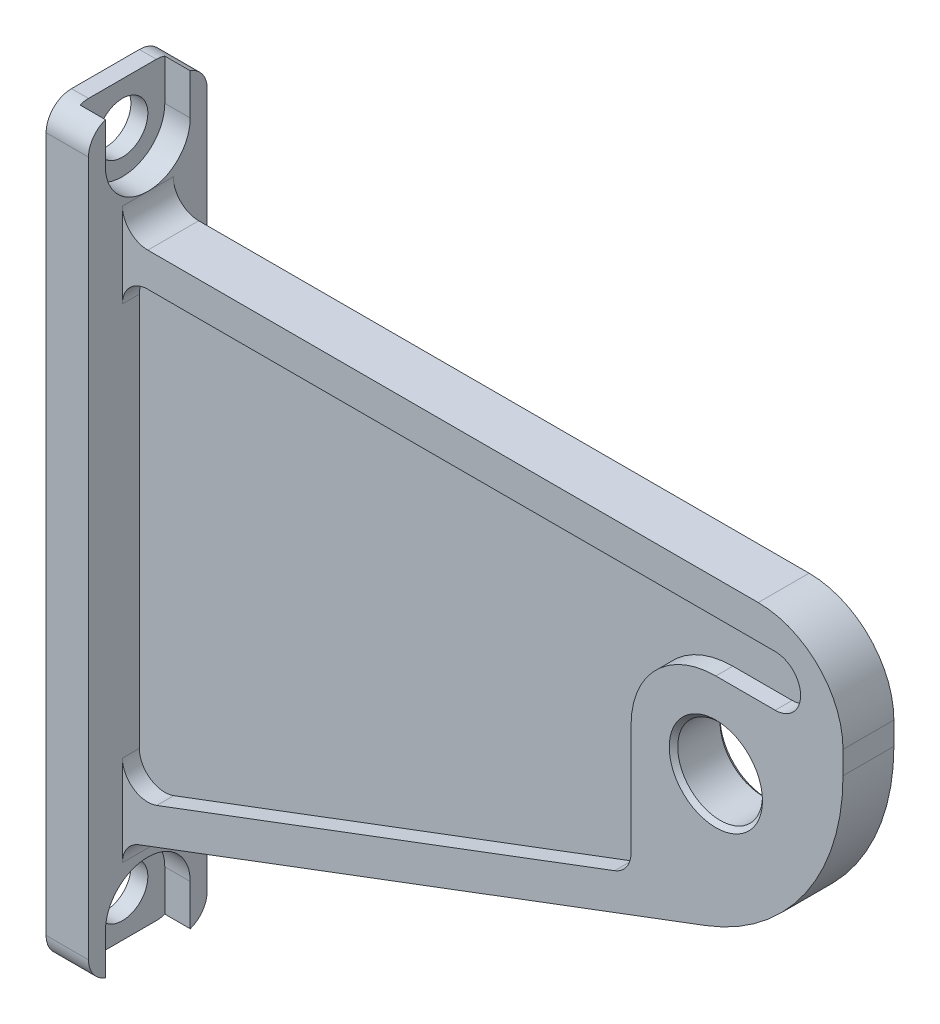
from build123d import *

# Parameters (mm, degrees)
EXTRUDE_2_DEPTH     = 7
SKETCH_2_10_R       = 5
EXTRUDE_6_DEPTH     = 3
EXTRUDE_7_DEPTH     = 1
SKETCH_5_R          = 3
CUT_EXTRUDE_1_DEPTH = 3
SKETCH_5_5_R        = 3
CUT_EXTRUDE_2_DEPTH = 123.547949799
FILLET_1_R          = 3
CHAMFER_2_SIZE      = 0.5


with BuildPart() as part:
    # Эскиз2 → Бобышка-Вытянуть2 (new, symmetric)
    with BuildSketch(Plane.XY):
        Polygon((5, 21.609375634), (5, 68), (5, 78), (5, 88), (0, 88), (0, 0), (5, 0), (5, 10.923979425), align=None)
    extrude(amount=EXTRUDE_2_DEPTH, both=True)

    # Эскиз2<10> → Бобышка-Вытянуть6 (add, symmetric)
    with BuildSketch(Plane.XY):
        with BuildLine():
            Line((82, 65), (75, 65))
            ThreePointArc((75, 65), (67.928932188, 62.071067812), (65, 55))
            Line((65, 55), (65, 41.942144818))
            ThreePointArc((65, 41.942144818), (64.466923843, 40.2350166), (63.057142165, 39.134574615))
            Line((63.057142165, 39.134574615), (9.057142165, 18.801805431))
            ThreePointArc((9.057142165, 18.801805431), (6.292871782, 19.142451791), (5, 21.609375634))
            Line((5, 21.609375634), (5, 10.923979425))
            ThreePointArc((5, 10.923979425), (5.533076157, 12.631107643), (6.942857835, 13.731549628))
            Line((6.942857835, 13.731549628), (73.80951804, 38.909037925))
            ThreePointArc((73.80951804, 38.909037925), (85.557698692, 48.079387798), (90, 62.305456282))
            Line((90, 62.305456282), (90, 65))
            ThreePointArc((90, 65), (87.071067812, 72.071067812), (80, 75))
            Line((80, 75), (8, 75))
            ThreePointArc((8, 75), (5.878679656, 75.878679656), (5, 78))
            Line((5, 78), (5, 68))
            ThreePointArc((5, 68), (5.878679656, 70.121320344), (8, 71))
            Line((8, 71), (82, 71))
            ThreePointArc((82, 71), (85, 68), (82, 65))
        make_face()
        with Locations((75, 55)):
            Circle(SKETCH_2_10_R, mode=Mode.SUBTRACT)
    extrude(amount=EXTRUDE_6_DEPTH, both=True)

    # Эскиз2<11> → Бобышка-Вытянуть7 (add, symmetric)
    with BuildSketch(Plane.XY):
        with BuildLine():
            ThreePointArc((65, 55), (67.928932188, 62.071067812), (75, 65))
            Line((75, 65), (82, 65))
            ThreePointArc((82, 65), (85, 68), (82, 71))
            Line((82, 71), (8, 71))
            ThreePointArc((8, 71), (5.878679656, 70.121320344), (5, 68))
            Line((5, 68), (5, 21.609375634))
            ThreePointArc((5, 21.609375634), (6.292871782, 19.142451791), (9.057142165, 18.801805431))
            Line((9.057142165, 18.801805431), (63.057142165, 39.134574615))
            ThreePointArc((63.057142165, 39.134574615), (64.466923843, 40.2350166), (65, 41.942144818))
            Line((65, 41.942144818), (65, 55))
        make_face()
    extrude(amount=EXTRUDE_7_DEPTH, both=True)

    # Эскиз5 → Вырез-Вытянуть1 (cut)
    # profile 1 of 2: a face of its own
    with BuildSketch(Plane(origin=(5, 0, 0), x_dir=(0, 0, -1), z_dir=(1, 0, 0))):
        with BuildLine():
            Line((-5, 0), (0, 0))
            Line((0, 0), (5, 0))
            Line((5, 0), (5, 5))
            ThreePointArc((5, 5), (0, 10), (-5, 5))
            Line((-5, 5), (-5, 0))
        make_face()
        with Locations((0, 5)):
            Circle(SKETCH_5_R, mode=Mode.SUBTRACT)
    # profile 2 of 2: a face of its own
    with BuildSketch(Plane(origin=(5, 0, 0), x_dir=(0, 0, -1), z_dir=(1, 0, 0))):
        with BuildLine():
            Line((-5, 88), (-5, 83))
            ThreePointArc((-5, 83), (0, 78), (5, 83))
            Line((5, 83), (5, 88))
            Line((5, 88), (-5, 88))
        make_face()
        with Locations((0, 83)):
            Circle(SKETCH_5_R, mode=Mode.SUBTRACT)
    extrude(amount=-CUT_EXTRUDE_1_DEPTH, mode=Mode.SUBTRACT)

    # Эскиз5<5> → Вырез-Вытянуть2 (cut, through all)
    with BuildSketch(Plane(origin=(5, 0, 0), x_dir=(0, 0, -1), z_dir=(1, 0, 0))):
        with Locations((0, 83)):
            Circle(SKETCH_5_5_R)
        with Locations((0, 5)):
            Circle(SKETCH_5_5_R)
    extrude(amount=-CUT_EXTRUDE_2_DEPTH, mode=Mode.SUBTRACT)

    # Скругление1
    fillet_1_edges = [part.edges().sort_by_distance(p)[0] for p in [
        (2.5, 0, 7),
        (2.5, 0, -7),
        (2.5, 88, -7),
        (2.5, 88, 7),
    ]]
    fillet(fillet_1_edges, radius=FILLET_1_R)

    # Фаска2
    chamfer_2_edges = [part.edges().sort_by_distance(p)[0] for p in [
        (70, 55, -3),
        (70, 55, 3),
    ]]
    chamfer(chamfer_2_edges, length=CHAMFER_2_SIZE)


solid = part.part
